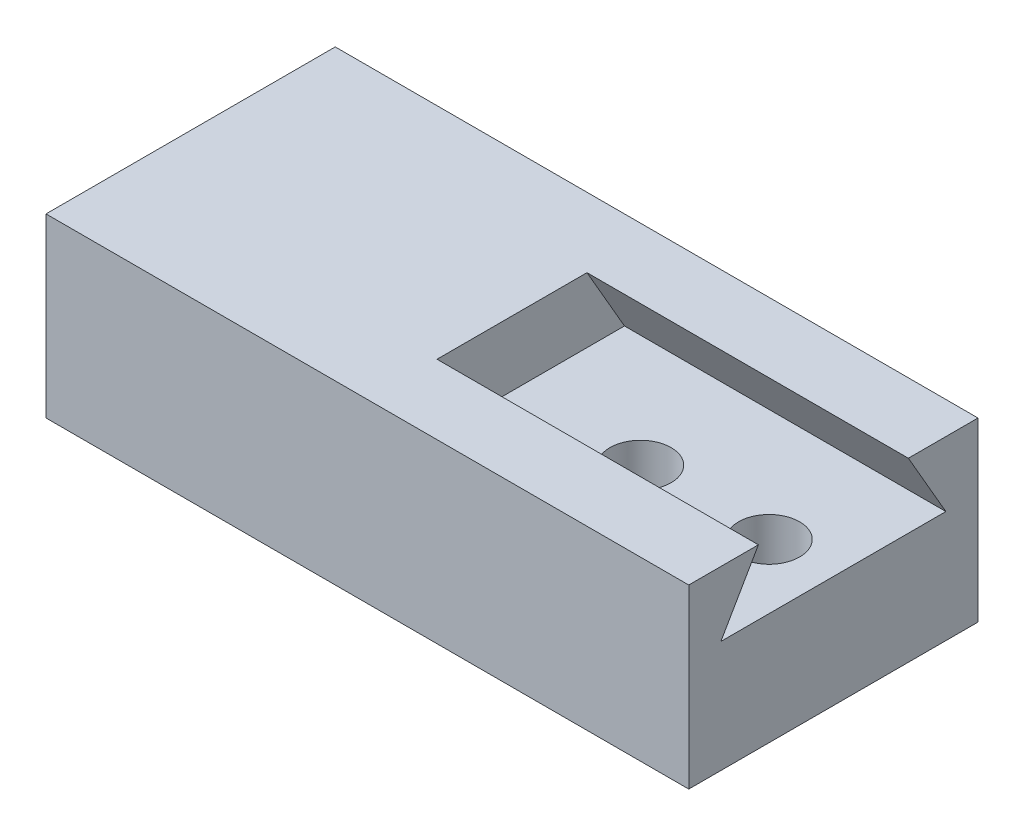
from build123d import *

# Parameters (mm, degrees)
BOSS_EXTRUDE1_DEPTH                = 5
BASE_SKETCH_4_W                    = 4.5
BASE_SKETCH_4_H                    = 2.75
BOSS_EXTRUDE2_DEPTH                = 5
TAP_DRILL_FOR_M1_2X0_25_TAP1_D     = 0.95
TAP_DRILL_FOR_M1_2X0_25_TAP1_DEPTH = 1.739637029


with BuildPart() as part:
    # base_sketch_3 → Boss-Extrude1 (new body)
    with BuildSketch(Plane(origin=(0, 0, 0), x_dir=(0, 0, -1), z_dir=(1, 0, 0))):
        Polygon((-1.75, -1.010362971), (-1.166666667, 0), (-2.25, 0), (-2.25, -2.75), (2.25, -2.75), (2.25, 0), (1.166666667, 0), (1.75, -1.010362971), align=None)
    extrude(amount=BOSS_EXTRUDE1_DEPTH)

    # base_sketch_4 → Boss-Extrude2 (add)
    with BuildSketch(Plane(origin=(0, 0, 0), x_dir=(0, 0, -1), z_dir=(1, 0, 0))):
        with Locations((0, -1.375)):
            Rectangle(BASE_SKETCH_4_W, BASE_SKETCH_4_H)
    extrude(amount=-BOSS_EXTRUDE2_DEPTH)

    # Tap Drill for M1.2x0.25 Tap1
    with Locations(Plane(origin=(0, -2.75, 0), x_dir=(-1, 0, 0), z_dir=(0, -1, 0))):
        with Locations((-4, 0), (-2, 0)):
            Hole(TAP_DRILL_FOR_M1_2X0_25_TAP1_D / 2, depth=TAP_DRILL_FOR_M1_2X0_25_TAP1_DEPTH)


solid = part.part
